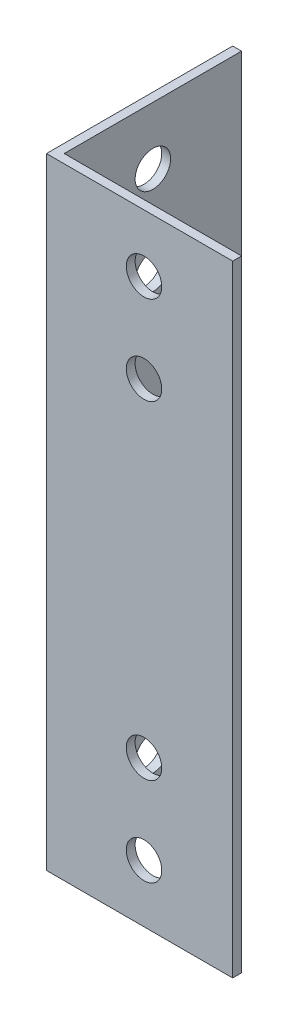
from build123d import *

# Parameters (mm, degrees)
EXTRUSION1_DEPTH = 70
EXTRUSION2_REACH = 3
ESQUISSE2_R      = 2
EXTRUSION3_REACH = 3
ESQUISSE3_R      = 2


with BuildPart() as part:
    # Esquisse1 → Extrusion1 (new body)
    with BuildSketch(Plane(origin=(0, 0, 0), x_dir=(1, 0, 0), z_dir=(0, 1, 0))):
        Polygon((0, 0), (0, 21), (1, 21), (1, 1), (21, 1), (21, 0), align=None)
    extrude(amount=EXTRUSION1_DEPTH)

    # Esquisse2 → Extrusion2 (cut, up to next)
    with BuildSketch(Plane(origin=(1, 0, 0), x_dir=(0, 0, -1), z_dir=(1, 0, 0)), mode=Mode.PRIVATE) as extrusion2_sk1:
        with Locations((11, 16.5)):
            Circle(ESQUISSE2_R)
    extrusion2_tool1 = extrude(extrusion2_sk1.sketch, amount=-EXTRUSION2_REACH, mode=Mode.PRIVATE) & part.part
    add(extrusion2_tool1.solids().sort_by_distance((1, 16.5, -11))[0], mode=Mode.SUBTRACT)
    # Esquisse2 → Extrusion2 (cut, up to next)
    with BuildSketch(Plane(origin=(1, 0, 0), x_dir=(0, 0, -1), z_dir=(1, 0, 0)), mode=Mode.PRIVATE) as extrusion2_sk2:
        with Locations((11, 6.5)):
            Circle(ESQUISSE2_R)
    extrusion2_tool2 = extrude(extrusion2_sk2.sketch, amount=-EXTRUSION2_REACH, mode=Mode.PRIVATE) & part.part
    add(extrusion2_tool2.solids().sort_by_distance((1, 6.5, -11))[0], mode=Mode.SUBTRACT)
    # Esquisse2 → Extrusion2 (cut, up to next)
    with BuildSketch(Plane(origin=(1, 0, 0), x_dir=(0, 0, -1), z_dir=(1, 0, 0)), mode=Mode.PRIVATE) as extrusion2_sk3:
        with Locations((11, 53.5)):
            Circle(ESQUISSE2_R)
    extrusion2_tool3 = extrude(extrusion2_sk3.sketch, amount=-EXTRUSION2_REACH, mode=Mode.PRIVATE) & part.part
    add(extrusion2_tool3.solids().sort_by_distance((1, 53.5, -11))[0], mode=Mode.SUBTRACT)
    # Esquisse2 → Extrusion2 (cut, up to next)
    with BuildSketch(Plane(origin=(1, 0, 0), x_dir=(0, 0, -1), z_dir=(1, 0, 0)), mode=Mode.PRIVATE) as extrusion2_sk4:
        with Locations((11, 63.5)):
            Circle(ESQUISSE2_R)
    extrusion2_tool4 = extrude(extrusion2_sk4.sketch, amount=-EXTRUSION2_REACH, mode=Mode.PRIVATE) & part.part
    add(extrusion2_tool4.solids().sort_by_distance((1, 63.5, -11))[0], mode=Mode.SUBTRACT)

    # Esquisse3 → Extrusion3 (cut, up to next)
    with BuildSketch(Plane(origin=(0, 0, -1), x_dir=(-1, 0, 0), z_dir=(0, 0, -1)), mode=Mode.PRIVATE) as extrusion3_sk1:
        with Locations((-11, 53.5)):
            Circle(ESQUISSE3_R)
    extrusion3_tool1 = extrude(extrusion3_sk1.sketch, amount=-EXTRUSION3_REACH, mode=Mode.PRIVATE) & part.part
    add(extrusion3_tool1.solids().sort_by_distance((11, 53.5, -1))[0], mode=Mode.SUBTRACT)
    # Esquisse3 → Extrusion3 (cut, up to next)
    with BuildSketch(Plane(origin=(0, 0, -1), x_dir=(-1, 0, 0), z_dir=(0, 0, -1)), mode=Mode.PRIVATE) as extrusion3_sk2:
        with Locations((-11, 63.5)):
            Circle(ESQUISSE3_R)
    extrusion3_tool2 = extrude(extrusion3_sk2.sketch, amount=-EXTRUSION3_REACH, mode=Mode.PRIVATE) & part.part
    add(extrusion3_tool2.solids().sort_by_distance((11, 63.5, -1))[0], mode=Mode.SUBTRACT)
    # Esquisse3 → Extrusion3 (cut, up to next)
    with BuildSketch(Plane(origin=(0, 0, -1), x_dir=(-1, 0, 0), z_dir=(0, 0, -1)), mode=Mode.PRIVATE) as extrusion3_sk3:
        with Locations((-11, 6.5)):
            Circle(ESQUISSE3_R)
    extrusion3_tool3 = extrude(extrusion3_sk3.sketch, amount=-EXTRUSION3_REACH, mode=Mode.PRIVATE) & part.part
    add(extrusion3_tool3.solids().sort_by_distance((11, 6.5, -1))[0], mode=Mode.SUBTRACT)
    # Esquisse3 → Extrusion3 (cut, up to next)
    with BuildSketch(Plane(origin=(0, 0, -1), x_dir=(-1, 0, 0), z_dir=(0, 0, -1)), mode=Mode.PRIVATE) as extrusion3_sk4:
        with Locations((-11, 16.5)):
            Circle(ESQUISSE3_R)
    extrusion3_tool4 = extrude(extrusion3_sk4.sketch, amount=-EXTRUSION3_REACH, mode=Mode.PRIVATE) & part.part
    add(extrusion3_tool4.solids().sort_by_distance((11, 16.5, -1))[0], mode=Mode.SUBTRACT)


solid = part.part
